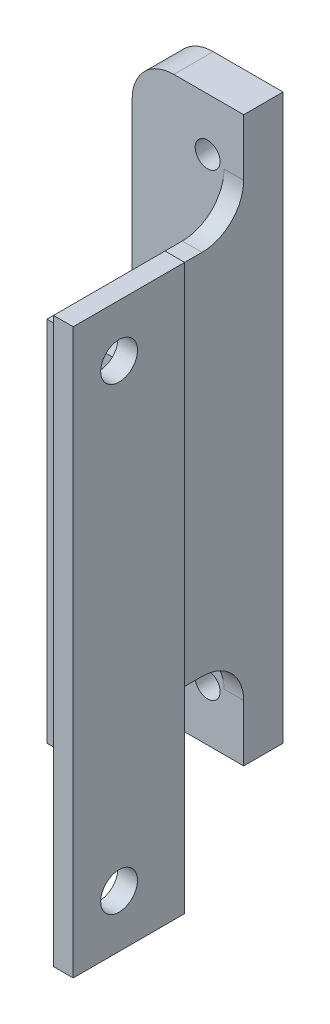
from build123d import *

# Parameters (mm, degrees)
EXTRUDE_THIN1_DEPTH        = 43
SKETCH7_W                  = 27
SKETCH7_H                  = 15
CUT_EXTRUDE3_DEPTH         = 15
FILLET1_R                  = 6.35
SKETCH11_W                 = 17
SKETCH11_H                 = 86
BOSS_EXTRUDE1_DEPTH        = 3
F_10_24_TAPPED_HOLE2_D     = 3.7973
FILLET2_R                  = 6.35
F_10_CLEARANCE_HOLE2_D     = 5.6134
F_10_CLEARANCE_HOLE2_DEPTH = 9.53
F_10_CLEARANCE_HOLE2_TIP   = 1.686435499


with BuildPart() as part:
    # Sketch1 → Extrude-Thin1 (new body, symmetric)
    with BuildSketch(Plane(origin=(0, 0, 0), x_dir=(1, 0, 0), z_dir=(0, 1, 0))):
        Polygon((0, 0), (0, 17), (-15, 17), (-15, 44), (-32, 44), (-32, 41), (-18, 41), (-18, 14), (-3, 14), (-3, 0), align=None)
    extrude(amount=EXTRUDE_THIN1_DEPTH, both=True)

    # Sketch7 → Cut-Extrude3 (cut)
    with BuildSketch(Plane.ZY.offset(18)):
        with Locations((-27.5, 35.5)):
            Rectangle(SKETCH7_W, SKETCH7_H)
    cut_extrude3 = extrude(amount=-CUT_EXTRUDE3_DEPTH, mode=Mode.SUBTRACT)

    # Mirror3: Cut-Extrude3 across plane
    add(cut_extrude3.mirror(Plane.ZX), mode=Mode.SUBTRACT)

    # Fillet1
    fillet1_edges = [part.edges().sort_by_distance(p)[0] for p in [
        (-16.5, 28, -41),
        (-16.5, -28, -41),
    ]]
    fillet(fillet1_edges, radius=FILLET1_R)

    # Sketch11 → Boss-Extrude1 (add)
    with BuildSketch(Plane(origin=(0, 0, -44), x_dir=(-1, 0, 0), z_dir=(0, 0, -1))):
        with Locations((23.5, 0)):
            Rectangle(SKETCH11_W, SKETCH11_H)
    extrude(amount=BOSS_EXTRUDE1_DEPTH)

    # #10-24 Tapped Hole2 (through all)
    with Locations(Plane(origin=(-13.4585207, 10.001554842, -47), x_dir=(-1, 0, 0), z_dir=(0, 0, -1))):
        with Locations((7.0414793, -27.001554842), (7.0414793, 24.998445158), (7.0414793, 6.998445158), (7.0414793, -45.001554842)):
            Hole(F_10_24_TAPPED_HOLE2_D / 2)

    # Fillet2
    fillet2_edges = [part.edges().sort_by_distance(p)[0] for p in [
        (-32, -43, -44),
        (-32, 43, -44),
    ]]
    fillet(fillet2_edges, radius=FILLET2_R)

    # #10 Clearance Hole2
    with Locations(Plane.ZY.offset(3)):
        with Locations((-7, -35), (-7, 35)):
            Hole(F_10_CLEARANCE_HOLE2_D / 2, depth=F_10_CLEARANCE_HOLE2_DEPTH)
            with Locations((0, 0, -(F_10_CLEARANCE_HOLE2_DEPTH + F_10_CLEARANCE_HOLE2_TIP / 2))):  # 118° drill point
                Cone(0, F_10_CLEARANCE_HOLE2_D / 2, F_10_CLEARANCE_HOLE2_TIP, mode=Mode.SUBTRACT)


solid = part.part
